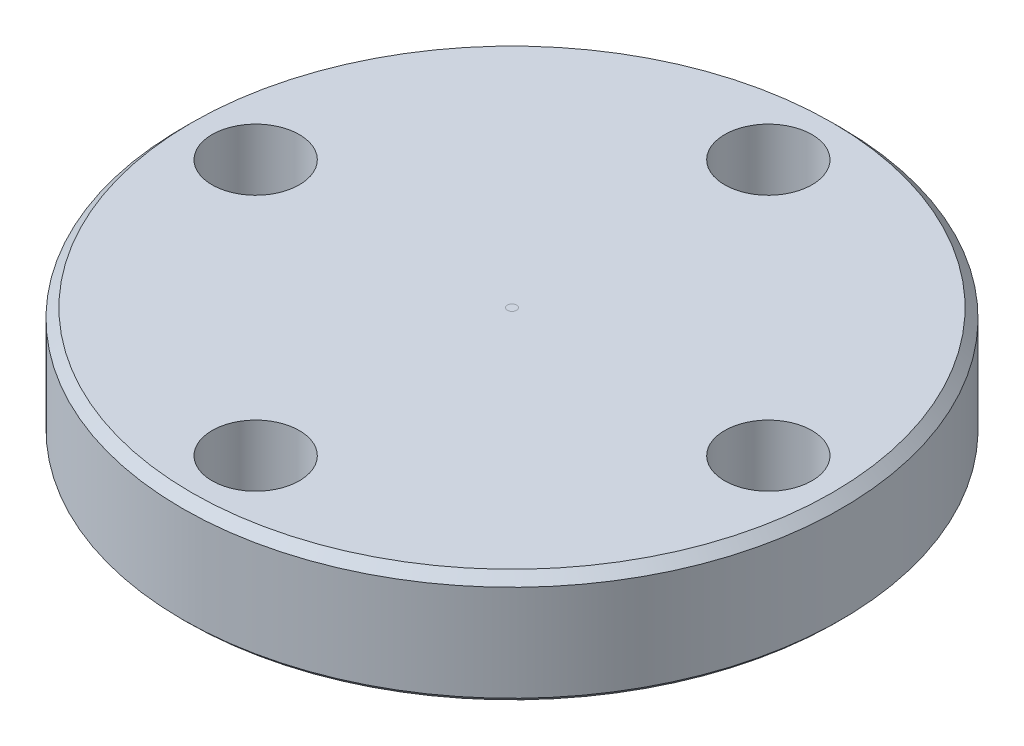
from build123d import *

# Parameters (mm, degrees)
SKETCH1_R           = 36
SKETCH1_R_2         = 0.5
BOSS_EXTRUDE1_DEPTH = 12
SKETCH4_R           = 4.765
CUT_EXTRUDE1_DEPTH  = 12
CIRPATTERN1_COUNT   = 4
CHAMFER1_SIZE       = 1
CHAMFER2_SIZE       = 0.5
SKETCH5_R           = 0.499735392
BOSS_EXTRUDE2_DEPTH = 12


with BuildPart() as part:
    # Sketch1 → Boss-Extrude1 (new body)
    with BuildSketch(Plane(origin=(0, 0, 0), x_dir=(1, 0, 0), z_dir=(0, 1, 0))):
        Circle(SKETCH1_R)
        Circle(SKETCH1_R_2, mode=Mode.SUBTRACT)
    extrude(amount=BOSS_EXTRUDE1_DEPTH)

    # Sketch4 → Cut-Extrude1 (cut)
    with BuildSketch(Plane(origin=(0, 12, 0), x_dir=(1, 0, 0), z_dir=(0, 1, 0))):
        with Locations((0, -28)):
            Circle(SKETCH4_R)
    cut_extrude1 = extrude(amount=-CUT_EXTRUDE1_DEPTH, mode=Mode.SUBTRACT)

    # CirPattern1: Cut-Extrude1 ×4 about axis
    cirpattern1_axis = Axis((0, 0, 0), (0, 1, 0))
    for i in range(1, CIRPATTERN1_COUNT):
        add(cut_extrude1.rotate(cirpattern1_axis, i * 360 / CIRPATTERN1_COUNT), mode=Mode.SUBTRACT)

    # Chamfer1
    chamfer1_edges = [part.edges().sort_by_distance(p)[0] for p in [
        (-36, 12, 0),
    ]]
    chamfer(chamfer1_edges, length=CHAMFER1_SIZE)

    # Chamfer2
    chamfer2_edges = [part.edges().sort_by_distance(p)[0] for p in [
        (-36, 0, 0),
    ]]
    chamfer(chamfer2_edges, length=CHAMFER2_SIZE)


with BuildPart() as body_2:
    # Sketch5 → Boss-Extrude2 (new body, through all)
    with BuildSketch(Plane(origin=(0, 0, 0), x_dir=(1, 0, 0), z_dir=(0, 1, 0))):
        Circle(SKETCH5_R)
    extrude(amount=BOSS_EXTRUDE2_DEPTH)


solid = Compound([part.part, body_2.part])
